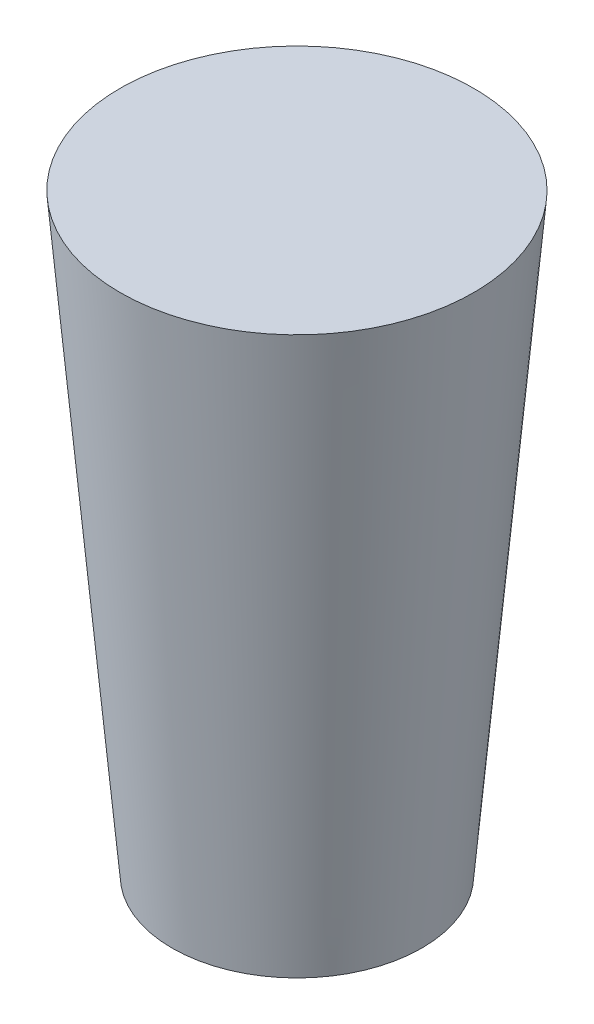
from build123d import *

# Parameters (mm, degrees)
SKETCH1_R           = 10.521996687
BOSS_EXTRUDE1_DEPTH = 50
BOSS_EXTRUDE1_TAPER = -5


with BuildPart() as part:
    # Sketch1 → Boss-Extrude1 (new body)
    with BuildSketch(Plane(origin=(0, 0, 0), x_dir=(1, 0, 0), z_dir=(0, 1, 0))):
        Circle(SKETCH1_R)
    extrude(amount=BOSS_EXTRUDE1_DEPTH, taper=BOSS_EXTRUDE1_TAPER)


solid = part.part
